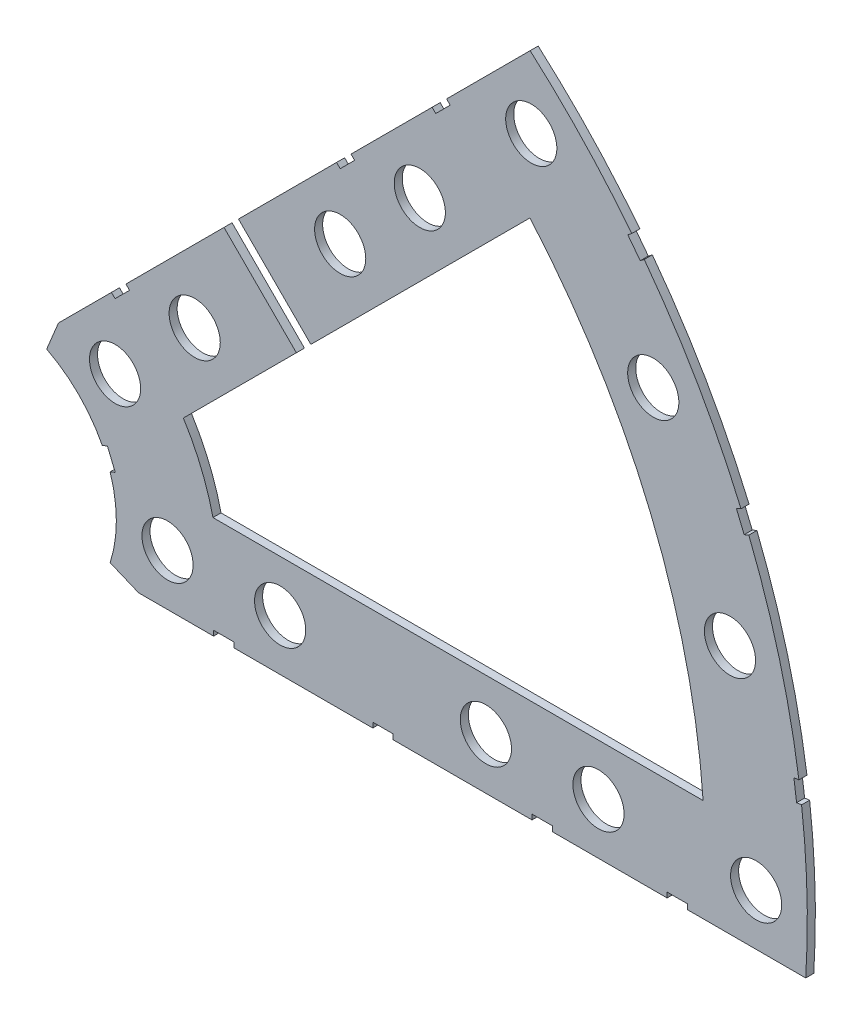
from build123d import *

# Parameters (mm, degrees)
BOSS_EXTRUDE1_DEPTH = 1
SKETCH2_R           = 3.175
CUT_EXTRUDE1_DEPTH  = 2
SKETCH3_W           = 2.54
SKETCH3_H           = 0.635
CUT_EXTRUDE2_DEPTH  = 2


with BuildPart() as part:
    # Sketch1 → Boss-Extrude1 (new body)
    with BuildSketch(Plane.XY):
        with BuildLine():
            Line((67.21146711, 76.191723231), (8.696654013, 17.676910134))
            Line((8.696654013, 17.676910134), (7.228954972, 14.133571205))
            ThreePointArc((7.228954972, 14.133571205), (14.666587579, 6.075099489), (15.105587123, -4.88230096))
            Line((15.105587123, -4.88230096), (18.648926052, -6.35))
            Line((18.648926052, -6.35), (101.401368334, -6.35))
            ThreePointArc((101.401368334, -6.35), (93.866160503, 38.880636728), (67.21146711, 76.191723231))
        make_face()
        with BuildLine():
            Line((88.672924278, 6.35), (27.86051193, 6.35))
            ThreePointArc((27.86051193, 6.35), (26.399857642, 10.93517908), (24.190484974, 15.210228852))
            Line((24.190484974, 15.210228852), (67.191354125, 58.211098004))
            ThreePointArc((67.191354125, 58.211098004), (82.13289044, 34.020557137), (88.672924278, 6.35))
        make_face(mode=Mode.SUBTRACT)
    extrude(amount=BOSS_EXTRUDE1_DEPTH)

    # Sketch2 → Cut-Extrude1 (cut, through all)
    with BuildSketch(Plane.XY.offset(1)):
        with Locations((22.225, 0)):
            Circle(SKETCH2_R)
        with Locations((36.195, 0)):
            Circle(SKETCH2_R)
        with Locations((61.722, 0)):
            Circle(SKETCH2_R)
        with Locations((75.692, 0)):
            Circle(SKETCH2_R)
        with Locations((95.25, 0)):
            Circle(SKETCH2_R)
        with Locations((15.715448212, 15.715448212)):
            Circle(SKETCH2_R)
        with Locations((25.593729945, 25.593729945)):
            Circle(SKETCH2_R)
        with Locations((43.644044748, 43.644044748)):
            Circle(SKETCH2_R)
        with Locations((53.522326482, 53.522326482)):
            Circle(SKETCH2_R)
        with Locations((92.004434954, 24.652514046)):
            Circle(SKETCH2_R)
        with Locations((82.48891971, 47.625)):
            Circle(SKETCH2_R)
        with Locations((67.351920908, 67.351920908)):
            Circle(SKETCH2_R)
    extrude(amount=-CUT_EXTRUDE1_DEPTH, mode=Mode.SUBTRACT)

    # Sketch3 → Cut-Extrude2 (cut, through all)
    with BuildSketch(Plane.XY.offset(1)):
        Polygon((15.266435406, 24.246691527), (17.06248663, 26.042742751), (17.511499436, 25.593729945), (15.715448212, 23.797678721), align=None)
        Polygon((44.991083167, 53.971339288), (43.195031942, 52.175288063), (43.644044748, 51.726275257), (45.440095973, 53.522326482), align=None)
        with Locations((29.21, -6.0325)):
            Rectangle(SKETCH3_W, SKETCH3_H)
        with Locations((68.707, -6.0325)):
            Rectangle(SKETCH3_W, SKETCH3_H)
        Polygon((29.230733674, 38.210989795), (31.026784898, 40.007041019), (40.007041019, 31.026784898), (38.210989795, 29.230733674), align=None)
        Polygon((56.845021246, 65.825277367), (55.048970022, 64.029226143), (55.497982828, 63.580213337), (57.294034052, 65.376264561), align=None)
        with Locations((48.9585, -6.0325)):
            Rectangle(SKETCH3_W, SKETCH3_H)
        with Locations((85.471, -6.0325)):
            Rectangle(SKETCH3_W, SKETCH3_H)
        Polygon((99.935462164, 14.437711971), (100.266998693, 11.919442024), (101.526133667, 12.085210288), (101.194597138, 14.603480236), align=None)
        Polygon((93.765504959, 37.464305742), (94.938831965, 37.950313702), (93.966816047, 40.296967714), (92.793489041, 39.810959755), align=None)
        Polygon((79.327792988, 62.471156422), (80.874047017, 60.456038938), (81.88160576, 61.229165953), (80.33535173, 63.244283437), align=None)
        Polygon((13.593916116, 7.005422516), (14.565932035, 4.658768503), (15.739259041, 5.144776462), (14.767243123, 7.491430475), align=None)
    extrude(amount=-CUT_EXTRUDE2_DEPTH, mode=Mode.SUBTRACT)


solid = part.part
